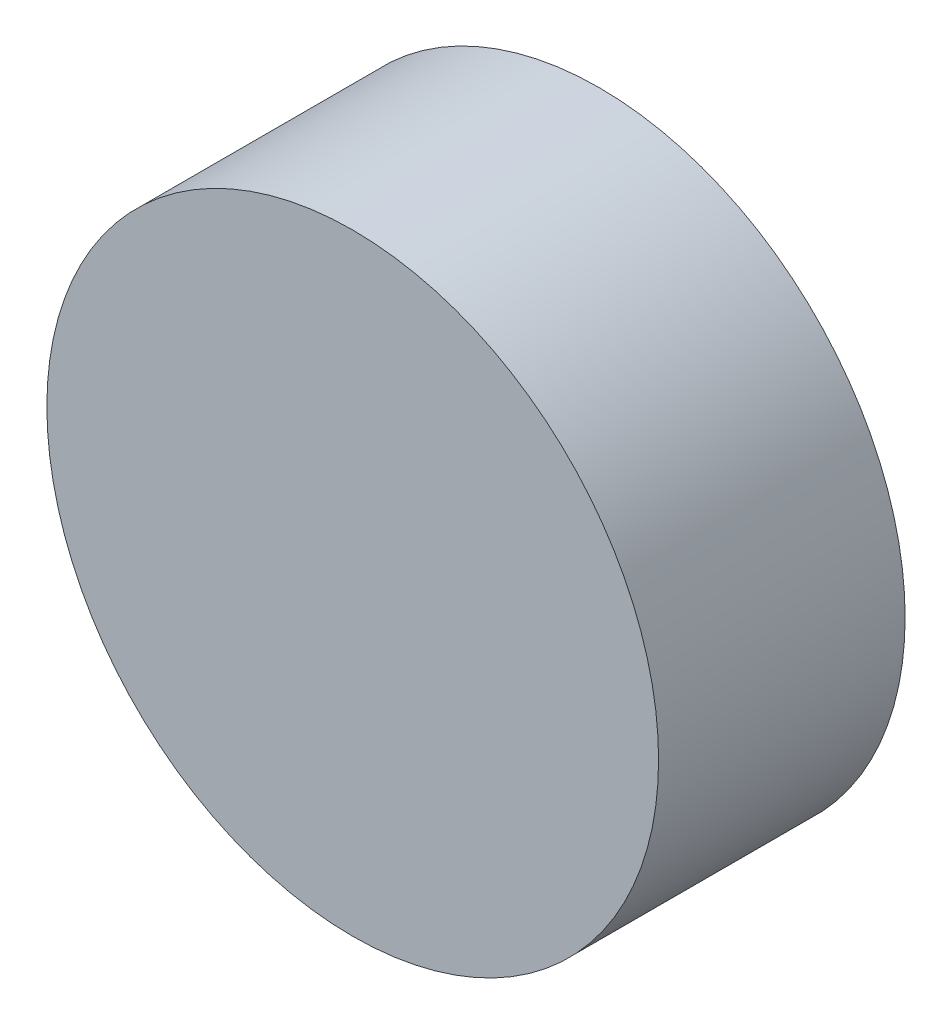
from build123d import *

# Parameters (mm, degrees)
SKETCH1_R           = 12.7
BOSS_EXTRUDE1_DEPTH = 10.237155


with BuildPart() as part:
    # Sketch1 → Boss-Extrude1 (new body)
    with BuildSketch(Plane.XY):
        with Locations((291.098437524, 204.55)):
            Circle(SKETCH1_R)
    extrude(amount=BOSS_EXTRUDE1_DEPTH)


solid = part.part
